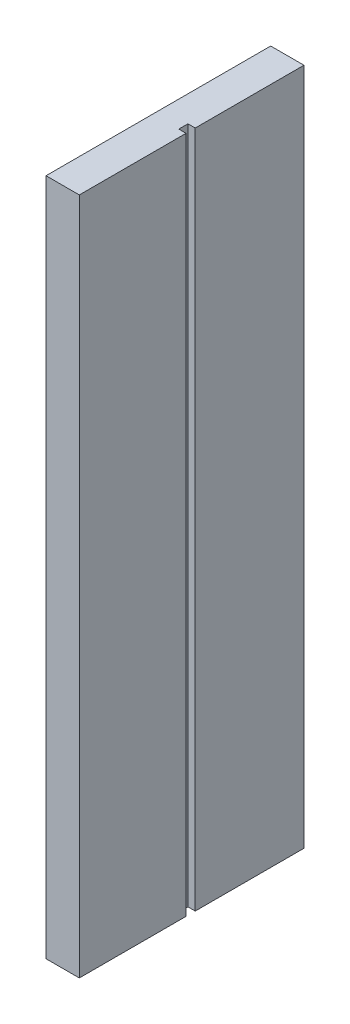
from build123d import *

# Parameters (mm, degrees)
EXTRUDE_1_DEPTH = 163
SKETCH_2_W      = 4.084844537
SKETCH_2_H      = 3.957854635
EXTRUDE_2_DEPTH = 2
SKETCH_3_W      = 4.4411109
SKETCH_3_H      = 4.15824399
EXTRUDE_3_DEPTH = 2
SKETCH_4_W      = 4.050772352
SKETCH_4_H      = 4.448077529
EXTRUDE_4_DEPTH = 2


with BuildPart() as part:
    # 草图1 → 凸台-拉伸1 (new body)
    with BuildSketch(Plane(origin=(0, 0, 0), x_dir=(1, 0, 0), z_dir=(0, 1, 0))):
        Polygon((0, -26.141443499), (-1.748690073, -26.141443499), (-1.748690073, -28.342387862), (0, -28.342387862), (0, -54), (-8, -54), (-8, 0), (0, 0), align=None)
    extrude(amount=-EXTRUDE_1_DEPTH)

    # 草图2 → 凸台-拉伸2 (add)
    with BuildSketch(Plane(origin=(0, 0, 0), x_dir=(-1, 0, 0), z_dir=(0, 0, -1))):
        with Locations((5.957577731, -20.96402105)):
            Rectangle(SKETCH_2_W, SKETCH_2_H)
    extrude(amount=EXTRUDE_2_DEPTH)

    # 草图3 → 凸台-拉伸3 (add)
    with BuildSketch(Plane(origin=(0, 0, 0), x_dir=(-1, 0, 0), z_dir=(0, 0, -1))):
        with Locations((5.77944455, -89.008990741)):
            Rectangle(SKETCH_3_W, SKETCH_3_H)
    extrude(amount=EXTRUDE_3_DEPTH)

    # 草图4 → 凸台-拉伸4 (add)
    with BuildSketch(Plane(origin=(0, 0, 0), x_dir=(-1, 0, 0), z_dir=(0, 0, -1))):
        with Locations((5.974613824, -143.08995755)):
            Rectangle(SKETCH_4_W, SKETCH_4_H)
    extrude(amount=EXTRUDE_4_DEPTH)


solid = part.part
